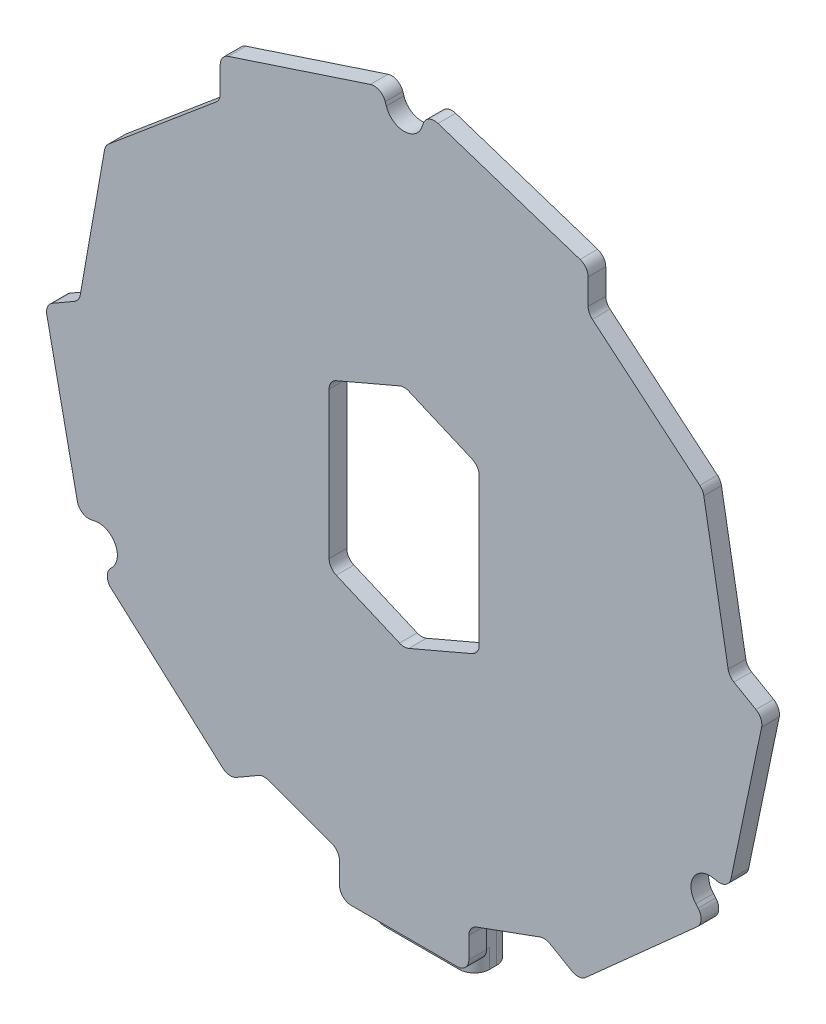
from build123d import *

# Parameters (mm, degrees)
BOSS_EXTRUDE1_DEPTH = 1.5
CUT_EXTRUDE1_DEPTH  = 2.5
CIRPATTERN1_COUNT   = 3
FILLET1_R           = 1
BOSS_EXTRUDE2_DEPTH = 3.17
FILLET2_R           = 1.3
SKETCH5_R           = 2
BOSS_EXTRUDE3_DEPTH = 3.17


with BuildPart() as part:
    # Sketch1 → Boss-Extrude1 (new body)
    with BuildSketch(Plane.XY):
        Polygon((7.362742618, 62.70624455), (-2.408800458, 54.506946358), (-4.623829447, 41.944892725), (-7.530430409, 40.266765877), (-4.165710563, 24.153038268), (8.106826973, 13.1822416), (11.013427935, 14.860368448), (17.5, 12.499449294), (17.5, 9), (28.5, 9), (28.5, 12.499449294), (34.986572065, 14.860368448), (37.893173027, 13.1822416), (50.165710563, 24.153038268), (53.530430409, 40.266765877), (50.623829447, 41.944892725), (48.408800458, 54.506946358), (38.637257382, 62.70624455), (38.637257382, 66.062498246), (23, 71.205429186), (7.362742618, 66.062498246), align=None)
        Polygon((23, 49.472293945), (16.618365096, 46.737307558), (16.618365096, 32.93702959), (23, 30.202043203), (29.381634904, 32.93702959), (29.381634904, 46.737307558), align=None, mode=Mode.SUBTRACT)
    extrude(amount=BOSS_EXTRUDE1_DEPTH)

    # Sketch2 → Cut-Extrude1 (cut, through all)
    with BuildSketch(Plane.XY.offset(1.5)):
        with BuildLine():
            Line((-4.580131881, 26.137712338), (-3.307805549, 26.403387777))
            ThreePointArc((-3.307805549, 26.403387777), (-1.595121467, 25.637168574), (-1.787898214, 23.770831049))
            Line((-1.787898214, 23.770831049), (-2.654143059, 22.801801844))
            Line((-2.654143059, 22.801801844), (-4.165710563, 24.153038268))
            Line((-4.165710563, 24.153038268), (-4.580131881, 26.137712338))
        make_face()
    cut_extrude1 = extrude(amount=-CUT_EXTRUDE1_DEPTH, mode=Mode.SUBTRACT)

    # CirPattern1: Cut-Extrude1 ×3 about axis
    cirpattern1_axis = Axis((23, 39.837168574, 0), (0, 0, 1))
    for i in range(1, CIRPATTERN1_COUNT):
        add(cut_extrude1.rotate(cirpattern1_axis, i * 360 / CIRPATTERN1_COUNT), mode=Mode.SUBTRACT)

    # Fillet1
    fillet1_edges = [part.edges().sort_by_distance(p)[0] for p in [
        (48.654143059, 22.801801844, 0.75),
        (50.580131881, 26.137712338, 0.75),
        (24.925988822, 70.571991541, 0.75),
        (21.074011178, 70.571991541, 0.75),
        (7.362742618, 66.062498246, 0.75),
        (38.637257382, 66.062498246, 0.75),
        (38.637257382, 62.70624455, 0.75),
        (48.408800458, 54.506946358, 0.75),
        (50.623829447, 41.944892725, 0.75),
        (53.530430409, 40.266765877, 0.75),
        (37.893173027, 13.1822416, 0.75),
        (34.986572065, 14.860368448, 0.75),
        (28.5, 12.499449294, 0.75),
        (28.5, 9, 0.75),
        (17.5, 9, 0.75),
        (17.5, 12.499449294, 0.75),
        (11.013427935, 14.860368448, 0.75),
        (8.106826973, 13.1822416, 0.75),
        (-7.530430409, 40.266765877, 0.75),
        (-4.623829447, 41.944892725, 0.75),
        (-2.408800458, 54.506946358, 0.75),
        (7.362742618, 62.70624455, 0.75),
        (16.618365096, 32.93702959, 0.75),
        (23, 30.202043203, 0.75),
        (29.381634904, 32.93702959, 0.75),
        (29.381634904, 46.737307558, 0.75),
        (23, 49.472293945, 0.75),
        (16.618365096, 46.737307558, 0.75),
        (-4.580131881, 26.137712338, 0.75),
        (-2.654143059, 22.801801844, 0.75),
    ]]
    fillet(fillet1_edges, radius=FILLET1_R)

    # Sketch4 → Boss-Extrude2 (add)
    with BuildSketch(Plane(origin=(0, 0, 0), x_dir=(-1, 0, 0), z_dir=(0, 0, -1))):
        Polygon((-27.47, 9), (-27.47, 7.38), (-18.53, 7.38), (-18.53, 9), (-18.53, 16.55), (-27.47, 16.55), align=None)
    extrude(amount=BOSS_EXTRUDE2_DEPTH)

    # Fillet2
    fillet2_edges = [part.edges().sort_by_distance(p)[0] for p in [
        (27.47, 8.19, 0),
        (18.53, 8.19, 0),
        (27.47, 11.965, -3.17),
        (18.53, 11.965, -3.17),
    ]]
    fillet(fillet2_edges, radius=FILLET2_R)

    # Sketch5 → Boss-Extrude3 (add)
    with BuildSketch(Plane(origin=(0, 0, 0), x_dir=(-1, 0, 0), z_dir=(0, 0, -1))):
        with Locations((-2.99, 46.937168574)):
            Circle(SKETCH5_R)
    extrude(amount=BOSS_EXTRUDE3_DEPTH)


solid = part.part
